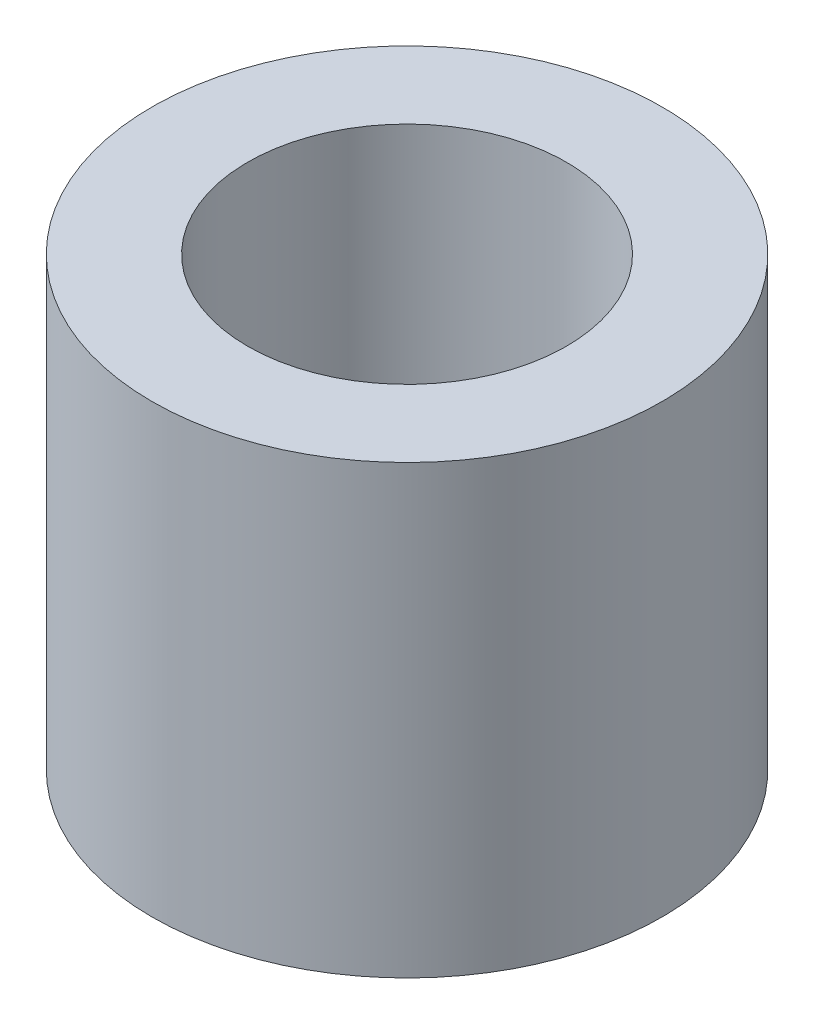
from build123d import *

# Parameters (mm, degrees)
SKETCH1_R           = 4
SKETCH1_R_2         = 2.5
BOSS_EXTRUDE1_DEPTH = 7


with BuildPart() as part:
    # Sketch1 → Boss-Extrude1 (new body)
    with BuildSketch(Plane(origin=(0, 0, 0), x_dir=(1, 0, 0), z_dir=(0, 1, 0))):
        Circle(SKETCH1_R)
        Circle(SKETCH1_R_2, mode=Mode.SUBTRACT)
    extrude(amount=BOSS_EXTRUDE1_DEPTH)


solid = part.part
